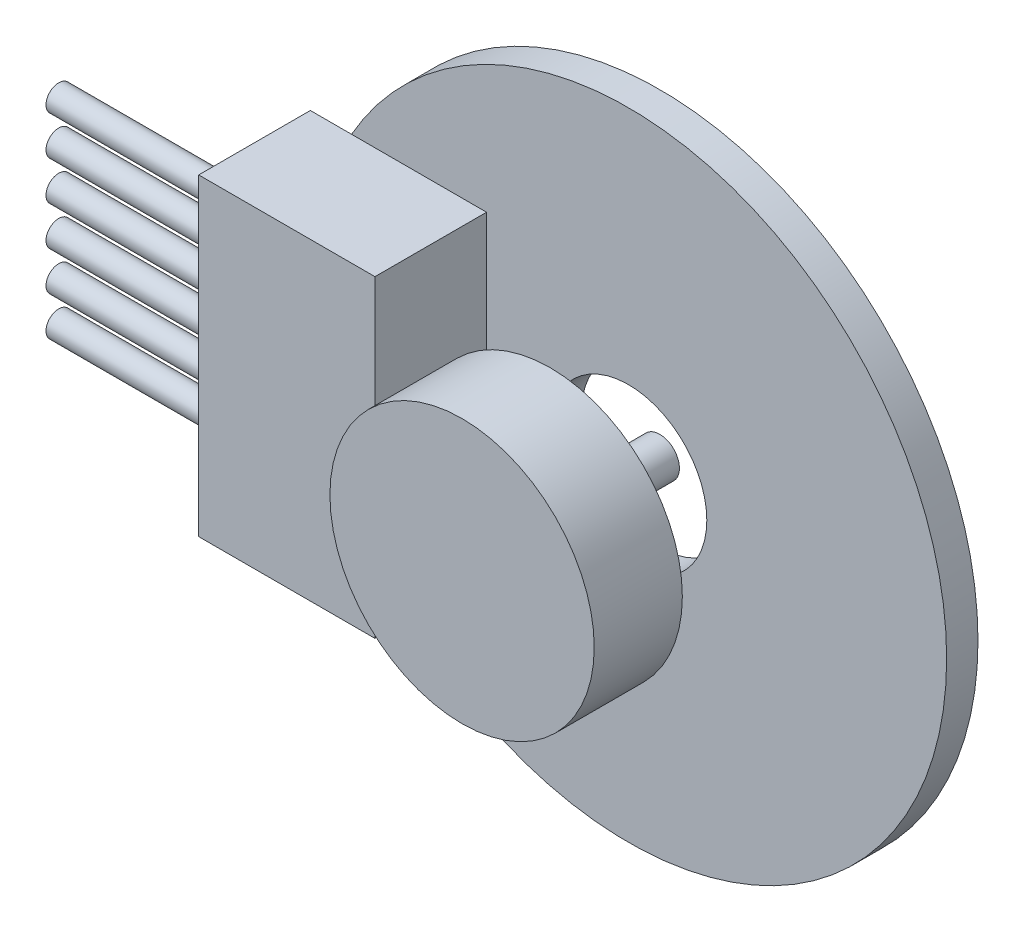
from build123d import *

# Parameters (mm, degrees)
SKETCH1_R           = 16.25
SKETCH1_R_2         = 4
BOSS_EXTRUDE1_DEPTH = 1.6
SKETCH2_W           = 9
SKETCH2_H           = 16
BOSS_EXTRUDE2_DEPTH = 5.7
SKETCH3_R           = 0.65
BOSS_EXTRUDE3_DEPTH = 10
SKETCH4_R           = 6.75
BOSS_EXTRUDE4_DEPTH = 4.5
SKETCH5_R           = 1
BOSS_EXTRUDE5_DEPTH = 5.6


with BuildPart() as part:
    # Sketch1 → Boss-Extrude1 (new body)
    with BuildSketch(Plane.XY):
        Circle(SKETCH1_R)
        Circle(SKETCH1_R_2, mode=Mode.SUBTRACT)
    extrude(amount=BOSS_EXTRUDE1_DEPTH)

    # Sketch2 → Boss-Extrude2 (add)
    with BuildSketch(Plane.XY.offset(1.6)):
        with Locations((-11.75, 0)):
            Rectangle(SKETCH2_W, SKETCH2_H)
    extrude(amount=BOSS_EXTRUDE2_DEPTH)

    # Sketch3 → Boss-Extrude3 (add)
    with BuildSketch(Plane.ZY.offset(16.25)):
        with Locations((4.45, 5)):
            Circle(SKETCH3_R)
        with Locations((4.45, 3)):
            Circle(SKETCH3_R)
        with Locations((4.45, 1)):
            Circle(SKETCH3_R)
        with Locations((4.45, -1)):
            Circle(SKETCH3_R)
        with Locations((4.45, -3)):
            Circle(SKETCH3_R)
        with Locations((4.45, -5)):
            Circle(SKETCH3_R)
    extrude(amount=BOSS_EXTRUDE3_DEPTH)


with BuildPart() as body_2:
    # Sketch4 → Boss-Extrude4 (new body)
    with BuildSketch(Plane.XY.offset(10.1)):
        Circle(SKETCH4_R)
    extrude(amount=-BOSS_EXTRUDE4_DEPTH)

    # Sketch5 → Boss-Extrude5 (add)
    with BuildSketch(Plane(origin=(0, 0, 5.6), x_dir=(-1, 0, 0), z_dir=(0, 0, -1))):
        Circle(SKETCH5_R)
    extrude(amount=BOSS_EXTRUDE5_DEPTH)


solid = Compound([part.part, body_2.part])
